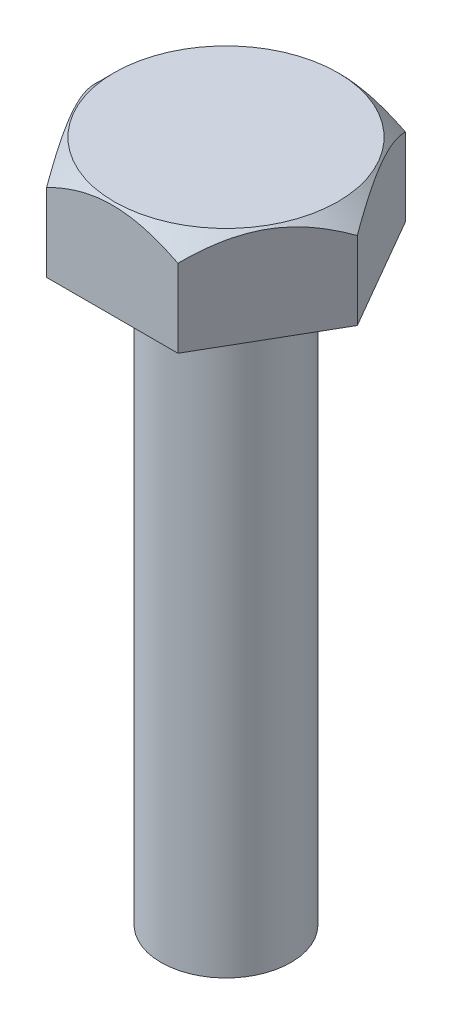
from build123d import *

# Parameters (mm, degrees)
SKETCH1_R           = 10
BOSS_EXTRUDE1_DEPTH = 105
BOSS_EXTRUDE2_DEPTH = 15


with BuildPart() as part:
    # Sketch1 → Boss-Extrude1 (new body)
    with BuildSketch(Plane(origin=(0, 0, 0), x_dir=(1, 0, 0), z_dir=(0, 1, 0))):
        Circle(SKETCH1_R)
    extrude(amount=BOSS_EXTRUDE1_DEPTH)

    # Sketch2 → Boss-Extrude2 (add)
    with BuildSketch(Plane(origin=(0, 105, 0), x_dir=(1, 0, 0), z_dir=(0, 1, 0))):
        Polygon((20.207259422, 0), (10.103629711, 17.5), (-10.103629711, 17.5), (-20.207259422, 0), (-10.103629711, -17.5), (10.103629711, -17.5), align=None)
    extrude(amount=-BOSS_EXTRUDE2_DEPTH)

    # Sketch3 → Cut-Revolve1 (revolve, cut)
    with BuildSketch(Plane.XY):
        Polygon((20.207259422, 105), (20.207259422, 102), (17.207259422, 105), align=None)
    revolve(axis=Axis((0, 0, 0), (0, 1, 0)), mode=Mode.SUBTRACT)


solid = part.part
